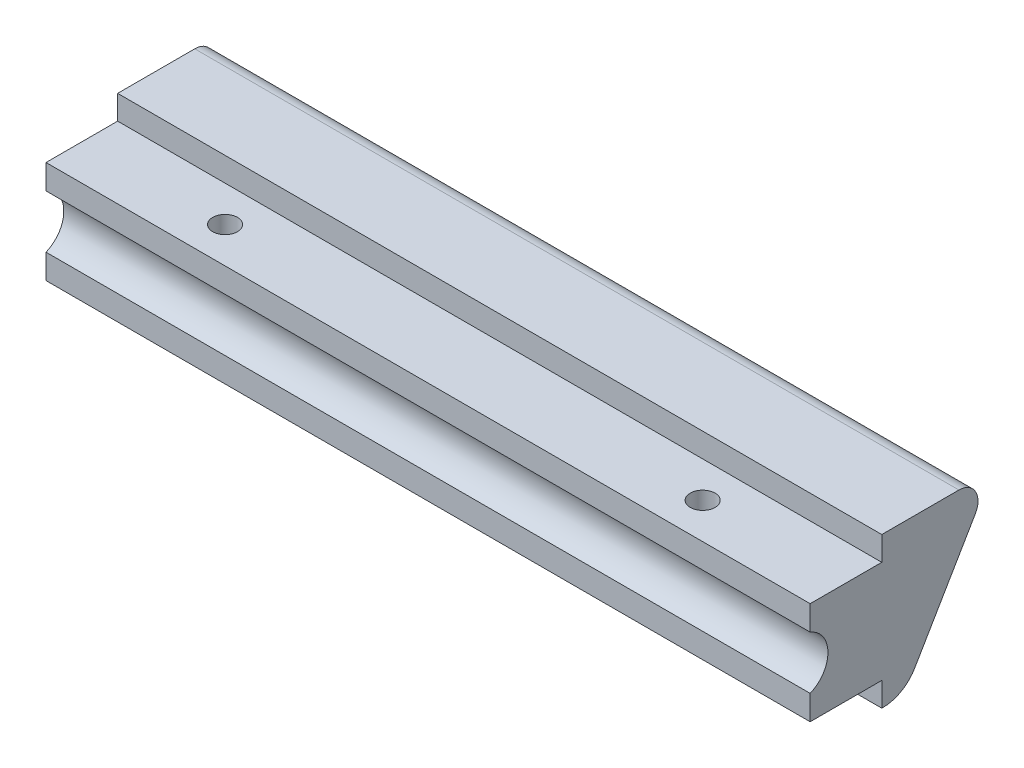
from build123d import *

# Parameters (mm, degrees)
BOSS_EXTRUDE1_DEPTH = 101.6
CUT_EXTRUDE2_DEPTH  = 101.6
SKETCH5_R           = 1.651
CUT_EXTRUDE3_DEPTH  = 13.5992
FILLET1_R           = 2.54


with BuildPart() as part:
    # Sketch1 → Boss-Extrude1 (new body)
    with BuildSketch(Plane(origin=(0, 0, 0), x_dir=(0, 0, -1), z_dir=(1, 0, 0))):
        with BuildLine():
            Line((0, 16.7996), (0, 3.2004))
            Line((0, 3.2004), (9.525, 3.2004))
            Line((9.525, 3.2004), (9.525, 0))
            Line((9.525, 0), (9.672001208, 0))
            ThreePointArc((9.672001208, 0), (12.1043061, 0.647018058), (13.89365381, 2.417039025))
            Line((13.89365381, 2.417039025), (24.215623453, 20))
            Line((24.215623453, 20), (9.525, 20))
            Line((9.525, 20), (9.525, 16.7996))
            Line((9.525, 16.7996), (0, 16.7996))
        make_face()
    extrude(amount=BOSS_EXTRUDE1_DEPTH)

    # Sketch4 → Cut-Extrude2 (cut)
    with BuildSketch(Plane.ZY):
        with BuildLine():
            Line((0, 13.526281186), (0, 6.473718814))
            ThreePointArc((0, 6.473718814), (-2.36728, 10), (0, 13.526281186))
        make_face()
    extrude(amount=-CUT_EXTRUDE2_DEPTH, mode=Mode.SUBTRACT)

    # Sketch5 → Cut-Extrude3 (cut)
    with BuildSketch(Plane(origin=(0, 16.7996, 0), x_dir=(1, 0, 0), z_dir=(0, 1, 0))):
        with Locations((19.05, 4.7625)):
            Circle(SKETCH5_R)
        with Locations((82.55, 4.7625)):
            Circle(SKETCH5_R)
    extrude(amount=-CUT_EXTRUDE3_DEPTH, mode=Mode.SUBTRACT)

    # Fillet1
    fillet1_edges = [part.edges().sort_by_distance(p)[0] for p in [
        (50.8, 20, -24.215623453),
    ]]
    fillet(fillet1_edges, radius=FILLET1_R)


solid = part.part
